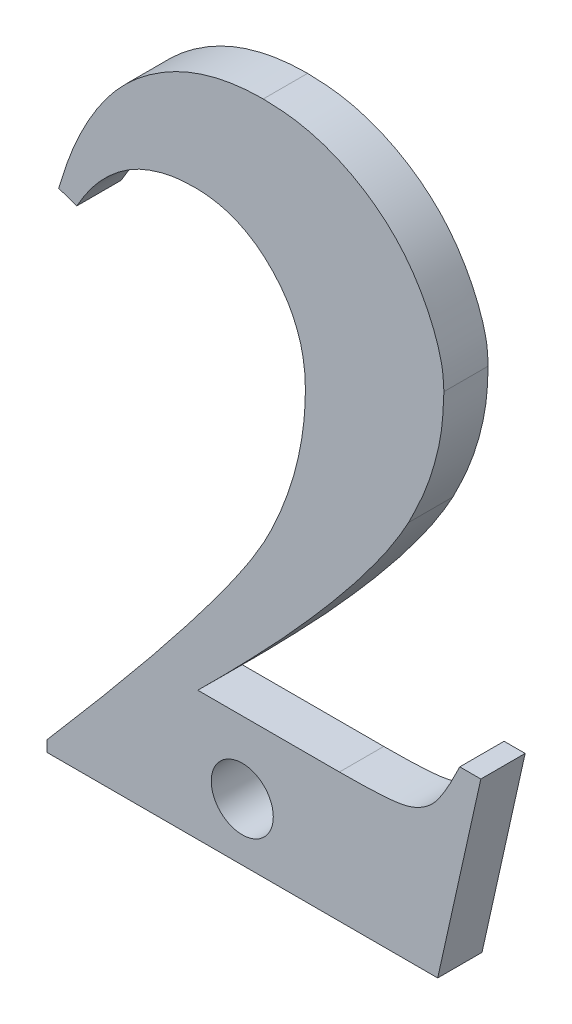
from build123d import *

# Parameters (mm, degrees)
BOSS_EXTRU_1_DEPTH     = 2
D_GAGEMENT_M1_61_D     = 2.8
D_GAGEMENT_M1_61_DEPTH = 50


with BuildPart() as part:
    # Esquisse1 → Boss.-Extru.1 (new body)
    with BuildSketch(Plane.XY):
        with BuildLine():
            Line((30.179082722, 11.205600965), (12.542363972, 11.205600965))
            Line((12.542363972, 11.205600965), (12.542363972, 11.693882215))
            add(Edge.make_bspline(
                [(12.542363972, 11.693882215), (12.881136709, 12.088648819), (13.542742266, 12.85960749), (14.508452904, 13.992781588), (15.418047611, 15.079454653), (16.277439508, 16.114606131), (17.087274316, 17.097820692), (17.840140522, 18.035083149), (18.546233089, 18.920390025), (19.194803638, 19.760040209), (19.797304838, 20.547404882), (20.339194184, 21.2889747), (20.841948632, 21.973542972), (21.277716543, 22.6165006), (21.676531137, 23.203798306), (22.009071616, 23.748203678), (22.301606172, 24.237636856), (22.610004896, 24.824218938), (22.935697027, 25.52406999), (23.275867169, 26.35140879), (23.564495095, 27.174588864), (23.798493759, 27.994304476), (23.982029168, 28.80936221), (24.112052658, 29.618129528), (24.193983215, 30.422653355), (24.204021871, 30.958014733), (24.209030639, 31.225132215)],
                knots=[0, 0, 0, 0, 0.0015606, 0.003047771, 0.004466519, 0.005811909, 0.007083975, 0.008287821, 0.009418461, 0.010481096, 0.011470701, 0.012392609, 0.013236481, 0.014018408, 0.014722618, 0.015365799, 0.015931906, 0.016432828, 0.017353171, 0.018246618, 0.019115508, 0.019968646, 0.020802615, 0.02162034, 0.022424923, 0.023226128, 0.023226128, 0.023226128, 0.023226128], degree=3))
            add(Edge.make_bspline(
                [(24.209030639, 31.225132215), (24.206655253, 31.414235122), (24.201968183, 31.787369618), (24.12375386, 32.332982208), (24.019318572, 32.858426919), (23.85158693, 33.35310546), (23.651423788, 33.825766135), (23.401285376, 34.273895228), (23.100563635, 34.693869832), (22.765183813, 35.090463219), (22.394783522, 35.445944183), (22.002313346, 35.762683678), (21.587212745, 36.028401492), (21.150868718, 36.246817438), (20.697063898, 36.416097723), (20.220705812, 36.533298704), (19.725615517, 36.606433615), (19.387236699, 36.616937759), (19.215541055, 36.622267631)],
                knots=[0, 0, 0, 0, 0.000566743, 0.001118287, 0.00165075, 0.002171624, 0.002681976, 0.00318912, 0.003707547, 0.004229397, 0.004745078, 0.005245322, 0.005740156, 0.006220562, 0.006706711, 0.007189888, 0.007689835, 0.008204817, 0.008204817, 0.008204817, 0.008204817], degree=3))
            add(Edge.make_bspline(
                [(19.215541055, 36.622267631), (18.936844993, 36.61344576), (18.389653493, 36.59612491), (17.597649359, 36.424792239), (16.849444788, 36.166203908), (16.151829751, 35.788732099), (15.506339966, 35.302359066), (14.907144288, 34.713738884), (14.356945555, 34.020964188), (14.04878719, 33.499173505), (13.890020222, 33.230340548)],
                knots=[0, 0, 0, 0, 0.000834959, 0.001639358, 0.002419767, 0.003203319, 0.004008008, 0.0048367, 0.00571722, 0.006653, 0.006653, 0.006653, 0.006653], degree=3))
            Line((13.890020222, 33.230340548), (13.076218139, 33.516798881))
            add(Edge.make_bspline(
                [(13.076218139, 33.516798881), (13.179054061, 33.852146444), (13.379157113, 34.504681753), (13.730639084, 35.441767759), (14.128497083, 36.308808373), (14.563282581, 37.10954717), (15.033600596, 37.844258143), (15.5420578, 38.513613494), (16.095126829, 39.111498004), (16.684071503, 39.642688482), (17.305618092, 40.104990045), (17.951897427, 40.51064322), (18.622014238, 40.85644043), (19.314800196, 41.13819172), (20.03030182, 41.35294052), (20.767979453, 41.510881359), (21.530961248, 41.602061284), (22.047337974, 41.615489489), (22.307988972, 41.622267631)],
                knots=[0, 0, 0, 0, 0.001052132, 0.00204729, 0.002999904, 0.003911781, 0.00477862, 0.005614594, 0.006430061, 0.00721836, 0.007990496, 0.00875099, 0.009505131, 0.010249855, 0.0109913, 0.011743387, 0.01251054, 0.013292467, 0.013292467, 0.013292467, 0.013292467], degree=3))
            add(Edge.make_bspline(
                [(22.307988972, 41.622267631), (22.679896981, 41.609915738), (23.413788868, 41.585541555), (24.487860289, 41.38745513), (25.508615399, 41.050279213), (26.468407849, 40.589262885), (27.355163704, 40.016933082), (28.150058294, 39.34282648), (28.841028925, 38.567355524), (29.408352915, 37.708211361), (29.86607553, 36.82218061), (30.202107309, 35.945268221), (30.419693518, 35.09420366), (30.446199504, 34.531420793), (30.459030639, 34.258986381)],
                knots=[0, 0, 0, 0, 0.001115183, 0.002200609, 0.003262944, 0.004331625, 0.005386232, 0.006420753, 0.00744909, 0.00849096, 0.009501334, 0.010434779, 0.011304864, 0.012121266, 0.012121266, 0.012121266, 0.012121266], degree=3))
            add(Edge.make_bspline(
                [(30.459030639, 34.258986381), (30.440330645, 33.771334999), (30.402419871, 32.782712091), (30.083359411, 31.300391879), (29.583549933, 29.80452581), (29.108010723, 28.841647649), (28.863978555, 28.347528048)],
                knots=[0, 0, 0, 0, 0.001461599, 0.002963122, 0.004529862, 0.006181366, 0.006181366, 0.006181366, 0.006181366], degree=3))
            add(Edge.make_bspline(
                [(28.863978555, 28.347528048), (28.76786982, 28.173010661), (28.56975854, 27.813273711), (28.23120618, 27.272143019), (27.865011588, 26.69861719), (27.444510098, 26.107661003), (26.987928456, 25.491384116), (26.501286537, 24.840310245), (25.957900083, 24.177108889), (25.388470702, 23.477928873), (24.771397811, 22.759712277), (24.117625487, 22.015788636), (23.425278319, 21.243370208), (22.689052157, 20.449438203), (21.91022666, 19.633010142), (21.091622049, 18.791368662), (20.243257466, 17.916656162), (19.65289757, 17.335092583), (19.352259805, 17.038934298)],
                knots=[0, 0, 0, 0, 0.000597577, 0.0012318, 0.001914401, 0.002638697, 0.003406954, 0.004215557, 0.005076755, 0.005978701, 0.006920711, 0.007917166, 0.008949842, 0.010032472, 0.011165284, 0.012334734, 0.013554755, 0.014820742, 0.014820742, 0.014820742, 0.014820742], degree=3))
            Line((19.352259805, 17.038934298), (25.745488972, 17.038934298))
            add(Edge.make_bspline(
                [(25.745488972, 17.038934298), (25.934313645, 17.037464211), (26.292485048, 17.034675682), (26.804467082, 17.053384982), (27.26500093, 17.059893125), (27.672690984, 17.089906602), (28.028799564, 17.114582451), (28.333895654, 17.142780825), (28.587044708, 17.1909813), (28.967040392, 17.271944811), (29.453325738, 17.483845597), (29.924483141, 17.844652989), (30.250271084, 18.262660952), (30.531456746, 18.706877056), (30.850559761, 19.283215692), (31.060390484, 19.717842386), (31.175176472, 19.955600965)],
                knots=[0, 0, 0, 0, 0.000566406, 0.001074386, 0.001536809, 0.001947791, 0.002300316, 0.002608033, 0.002865996, 0.003072901, 0.003773035, 0.00443598, 0.00482947, 0.005356773, 0.006012518, 0.006804464, 0.006804464, 0.006804464, 0.006804464], degree=3))
            Line((31.175176472, 19.955600965), (32.125697305, 19.955600965))
            Line((32.125697305, 19.955600965), (30.179082722, 11.205600965))
        make_face()
    extrude(amount=BOSS_EXTRU_1_DEPTH)

    # Dégagement M1.61
    with Locations(Plane.XY.offset(2)):
        with Locations((21.360723347, 13.792257827)):
            Hole(D_GAGEMENT_M1_61_D / 2, depth=D_GAGEMENT_M1_61_DEPTH)


solid = part.part
